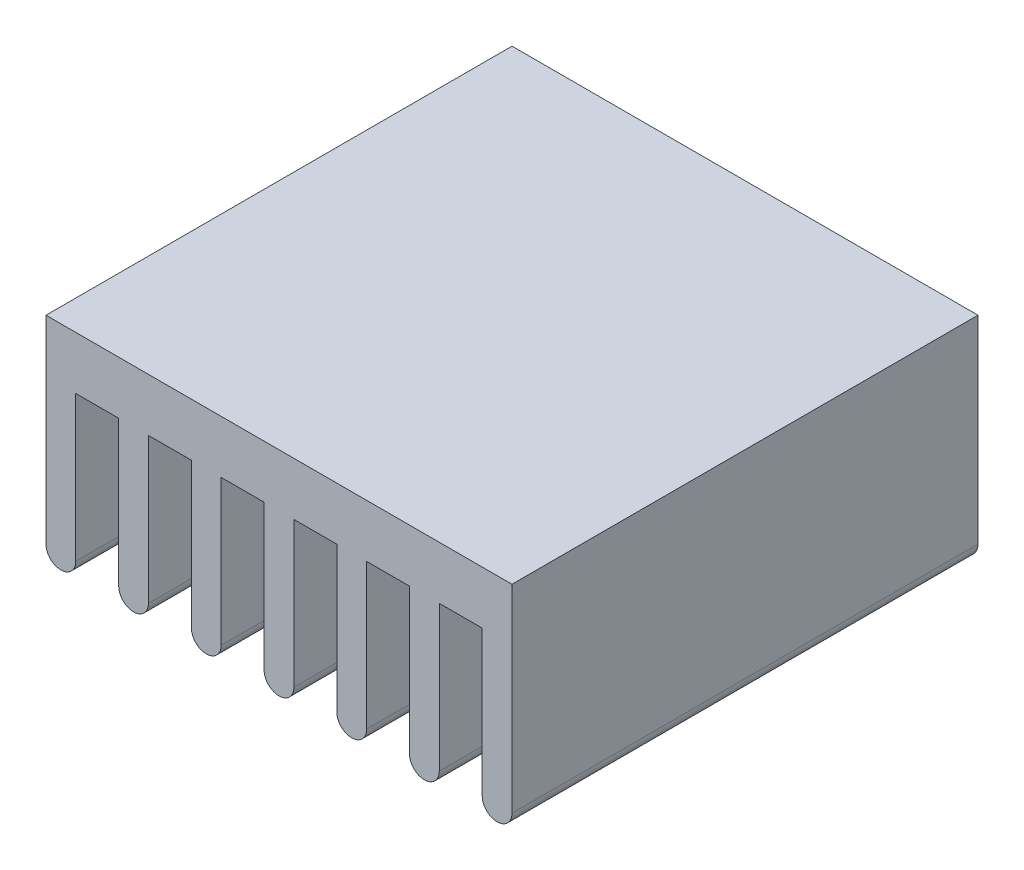
from build123d import *

# Parameters (mm, degrees)
BOSS_EXTRUDE1_DEPTH = 14.1


with BuildPart() as part:
    # Esboço1 → Boss-Extrude1 (new body)
    with BuildSketch(Plane.XY):
        with BuildLine():
            Line((0, 0), (14.098810584, 0))
            Line((14.098810584, 0), (14.098810584, -6))
            ThreePointArc((14.098810584, -6), (13.648810584, -6.45), (13.198810584, -6))
            Line((13.198810584, -6), (13.198810584, -1.6))
            Line((13.198810584, -1.6), (11.898810584, -1.6))
            Line((11.898810584, -1.6), (11.898810584, -6))
            ThreePointArc((11.898810584, -6), (11.448810584, -6.45), (10.998810584, -6))
            Line((10.998810584, -6), (10.998810584, -1.6))
            Line((10.998810584, -1.6), (9.698810584, -1.6))
            Line((9.698810584, -1.6), (9.698810584, -6))
            ThreePointArc((9.698810584, -6), (9.249405292, -6.449405292), (8.8, -6))
            Line((8.8, -6), (8.8, -1.6))
            Line((8.8, -1.6), (7.5, -1.6))
            Line((7.5, -1.6), (7.5, -6))
            ThreePointArc((7.5, -6), (7.05, -6.45), (6.6, -6))
            Line((6.6, -6), (6.6, -1.6))
            Line((6.6, -1.6), (5.3, -1.6))
            Line((5.3, -1.6), (5.3, -6))
            ThreePointArc((5.3, -6), (4.85, -6.45), (4.4, -6))
            Line((4.4, -6), (4.4, -1.6))
            Line((4.4, -1.6), (3.1, -1.6))
            Line((3.1, -1.6), (3.1, -6))
            ThreePointArc((3.1, -6), (2.65, -6.45), (2.2, -6))
            Line((2.2, -6), (2.2, -1.6))
            Line((2.2, -1.6), (0.9, -1.6))
            Line((0.9, -1.6), (0.9, -6))
            ThreePointArc((0.9, -6), (0.45, -6.45), (0, -6))
            Line((0, -6), (0, 0))
        make_face()
    extrude(amount=BOSS_EXTRUDE1_DEPTH)


solid = part.part
